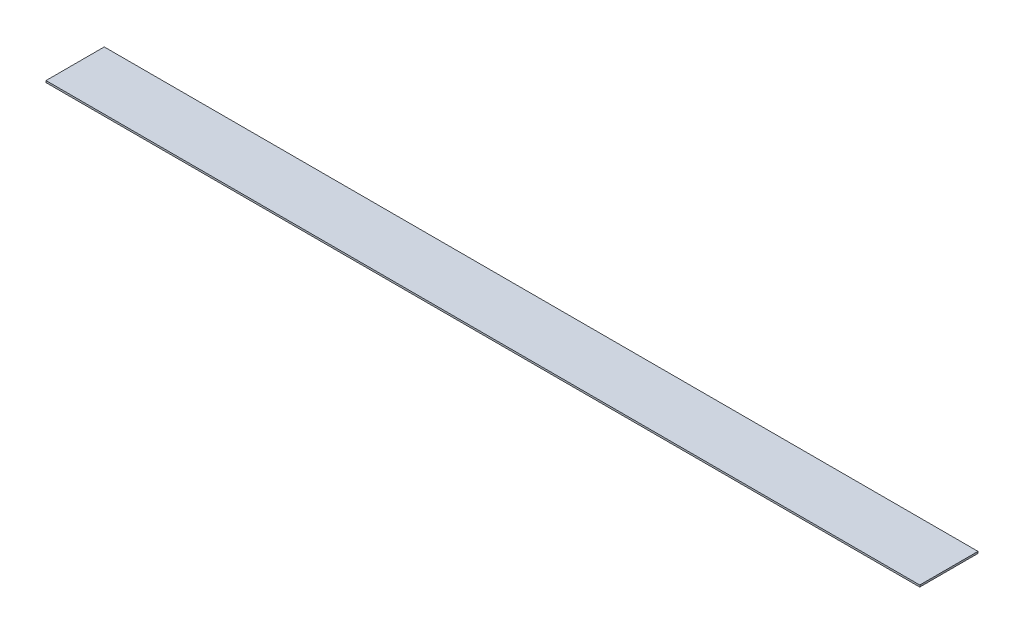
from build123d import *

# Parameters (mm, degrees)
SKETCH1_W           = 762
SKETCH1_H           = 50.8
BOSS_EXTRUDE1_DEPTH = 1.5875


with BuildPart() as part:
    # Sketch1 → Boss-Extrude1 (new body)
    with BuildSketch(Plane(origin=(0, 0, 0), x_dir=(1, 0, 0), z_dir=(0, 1, 0))):
        with Locations((381, 25.4)):
            Rectangle(SKETCH1_W, SKETCH1_H)
    extrude(amount=BOSS_EXTRUDE1_DEPTH)


solid = part.part
